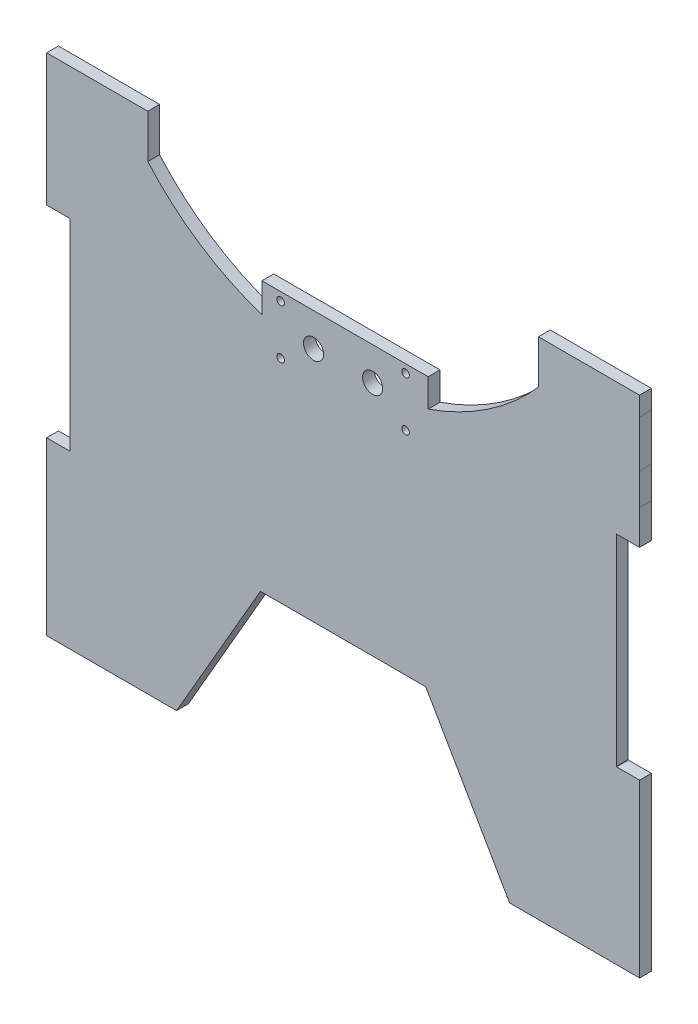
from build123d import *

# Parameters (mm, degrees)
BOSS_EXTRUDE1_DEPTH = 5
SKETCH2_W           = 70.400327135
SKETCH2_H           = 34
SKETCH2_R           = 1.6
SKETCH2_R_2         = 4.25
BOSS_EXTRUDE2_DEPTH = 5
SKETCH3_W           = 34.735720487
SKETCH3_H           = 8.029761027
BOSS_EXTRUDE3_DEPTH = 5
BOSS_EXTRUDE4_DEPTH = 5


with BuildPart() as part:
    # Sketch1 → Boss-Extrude1 (new body)
    with BuildSketch(Plane.XY):
        with BuildLine():
            Line((-91.722809189, 104.356193097), (-126.458529676, 104.356193097))
            Line((-126.458529676, 104.356193097), (-126.475267186, 84.614358359))
            Line((-126.475267186, 84.614358359), (-126.480371779, 71.180735955))
            Line((-126.480371779, 71.180735955), (-126.480681684, 56.559478315))
            Line((-126.480681684, 56.559478315), (-116.63815349, 56.559478315))
            Line((-116.63815349, 56.559478315), (-116.63815349, -28.787570067))
            Line((-116.63815349, -28.787570067), (-126.481949379, -28.787570067))
            Line((-126.481949379, -28.787570067), (-126.481949379, -101.34405192))
            Line((-126.481949379, -101.34405192), (-71.448987089, -101.34405192))
            Line((-71.448987089, -101.34405192), (-35.928248301, -39.820327617))
            Line((-35.928248301, -39.820327617), (34.075825089, -39.820327617))
            Line((34.075825089, -39.820327617), (69.596563877, -101.34405192))
            Line((69.596563877, -101.34405192), (124.629526167, -101.34405192))
            Line((124.629526167, -101.34405192), (124.629526167, -28.787570067))
            Line((124.629526167, -28.787570067), (114.912707304, -28.787570067))
            ThreePointArc((114.912707304, -28.787570067), (114.822920988, -28.750379358), (114.785730279, -28.660593042))
            Line((114.785730279, -28.660593042), (114.785730279, 56.432501289))
            ThreePointArc((114.785730279, 56.432501289), (114.822920988, 56.522287605), (114.912707304, 56.559478315))
            Line((114.912707304, 56.559478315), (124.628258473, 56.559478315))
            Line((124.628258473, 56.559478315), (124.627948781, 71.170673702))
            Line((124.627948781, 71.170673702), (124.622835448, 84.62441506))
            Line((124.622835448, 84.62441506), (124.606106464, 104.356193097))
            Line((124.606106464, 104.356193097), (89.870385977, 104.356193097))
            ThreePointArc((89.870385977, 104.356193097), (65.84204117, 79.034177757), (35.089604597, 62.515901216))
            Line((35.089604597, 62.515901216), (35.089604597, 40.385954124))
            Line((35.089604597, 40.385954124), (-35.310722538, 40.385954124))
            Line((-35.310722538, 40.385954124), (-35.310722538, 61.964889462))
            ThreePointArc((-35.310722538, 61.964889462), (-67.008229873, 78.514287134), (-91.722809189, 104.356193097))
        make_face()
    extrude(amount=BOSS_EXTRUDE1_DEPTH)

    # Sketch2 → Boss-Extrude2 (add)
    with BuildSketch(Plane.XY.offset(5)):
        with Locations((-0.11055897, 57.385954124)):
            Rectangle(SKETCH2_W, SKETCH2_H)
        with Locations((-27.3906777, 70.850420218)):
            Circle(SKETCH2_R, mode=Mode.SUBTRACT)
        with Locations((-27.3906777, 49.92148803)):
            Circle(SKETCH2_R, mode=Mode.SUBTRACT)
        with Locations((25.538254488, 49.92148803)):
            Circle(SKETCH2_R, mode=Mode.SUBTRACT)
        with Locations((25.538254488, 70.850420218)):
            Circle(SKETCH2_R, mode=Mode.SUBTRACT)
        with Locations((-13.426211606, 60.385954124)):
            Circle(SKETCH2_R_2, mode=Mode.SUBTRACT)
        with Locations((11.573788394, 60.385954124)):
            Circle(SKETCH2_R_2, mode=Mode.SUBTRACT)
    extrude(amount=-BOSS_EXTRUDE2_DEPTH)

    # Sketch3 → Boss-Extrude3 (add)
    with BuildSketch(Plane.XY.offset(5)):
        with Locations((-109.090669433, 108.371073611)):
            Rectangle(SKETCH3_W, SKETCH3_H)
        with Locations((107.238246221, 108.371073611)):
            Rectangle(SKETCH3_W, SKETCH3_H)
    extrude(amount=-BOSS_EXTRUDE3_DEPTH)

    # Sketch4 → Boss-Extrude4 (add)
    with BuildSketch(Plane.XY.offset(5)):
        with BuildLine():
            Line((89.870385977, 112.385954124), (81.785730279, 112.385954124))
            Line((81.785730279, 112.385954124), (81.785730279, 93.935580042))
            ThreePointArc((81.785730279, 93.935580042), (85.984378147, 99.024608337), (89.870385977, 104.356193097))
            Line((89.870385977, 104.356193097), (89.870385977, 112.385954124))
        make_face()
        with BuildLine():
            Line((-91.722809189, 112.385954124), (-91.722809189, 104.356193097))
            ThreePointArc((-91.722809189, 104.356193097), (-87.836801358, 99.024608337), (-83.63815349, 93.935580042))
            Line((-83.63815349, 93.935580042), (-83.63815349, 112.385954124))
            Line((-83.63815349, 112.385954124), (-91.722809189, 112.385954124))
        make_face()
    extrude(amount=-BOSS_EXTRUDE4_DEPTH)


solid = part.part
